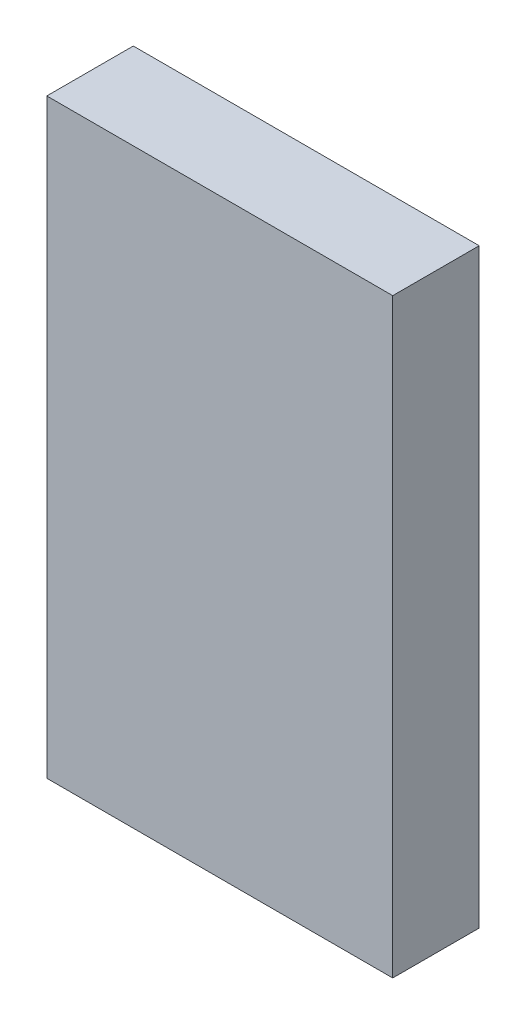
from build123d import *

# Parameters (mm, degrees)
SKETCH1_W           = 120
SKETCH1_H           = 205
BOSS_EXTRUDE1_DEPTH = 30


with BuildPart() as part:
    # Sketch1 → Boss-Extrude1 (new body)
    with BuildSketch(Plane.XY):
        with Locations((60, -102.5)):
            Rectangle(SKETCH1_W, SKETCH1_H)
    extrude(amount=BOSS_EXTRUDE1_DEPTH)


solid = part.part
